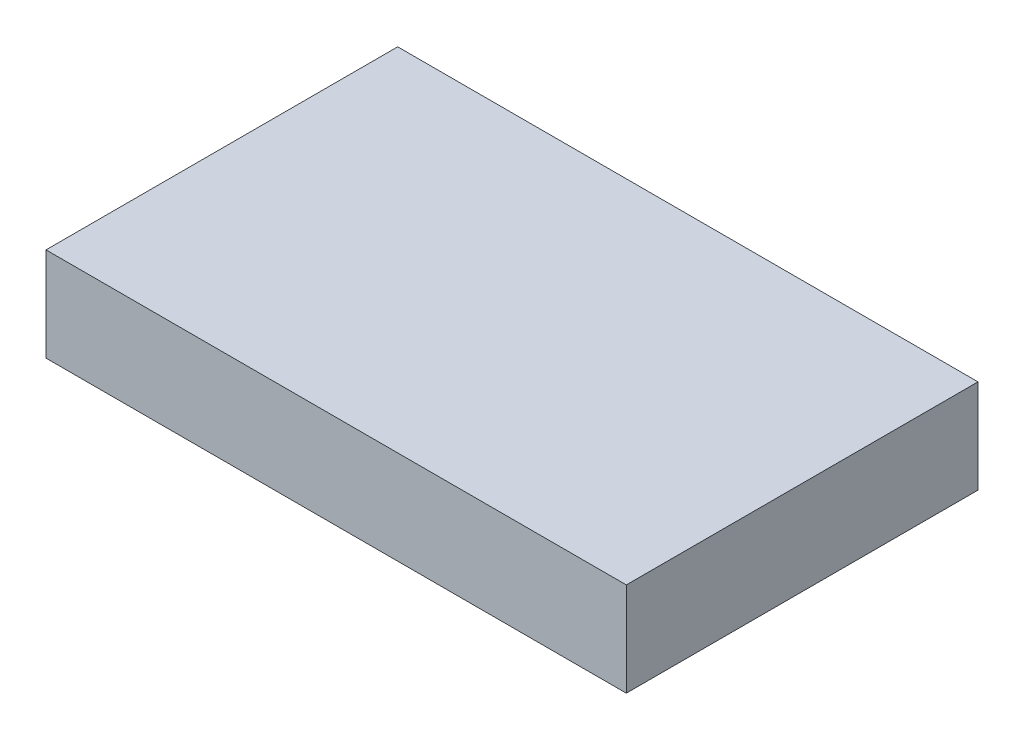
from build123d import *

# Parameters (mm, degrees)
SKETCH1_W           = 9.9
SKETCH1_H           = 6
BOSS_EXTRUDE1_DEPTH = 1.6


with BuildPart() as part:
    # Sketch1 → Boss-Extrude1 (new body)
    with BuildSketch(Plane(origin=(0, 0, 0), x_dir=(1, 0, 0), z_dir=(0, 1, 0))):
        with Locations((4.95, 3)):
            Rectangle(SKETCH1_W, SKETCH1_H)
    extrude(amount=BOSS_EXTRUDE1_DEPTH)


solid = part.part
